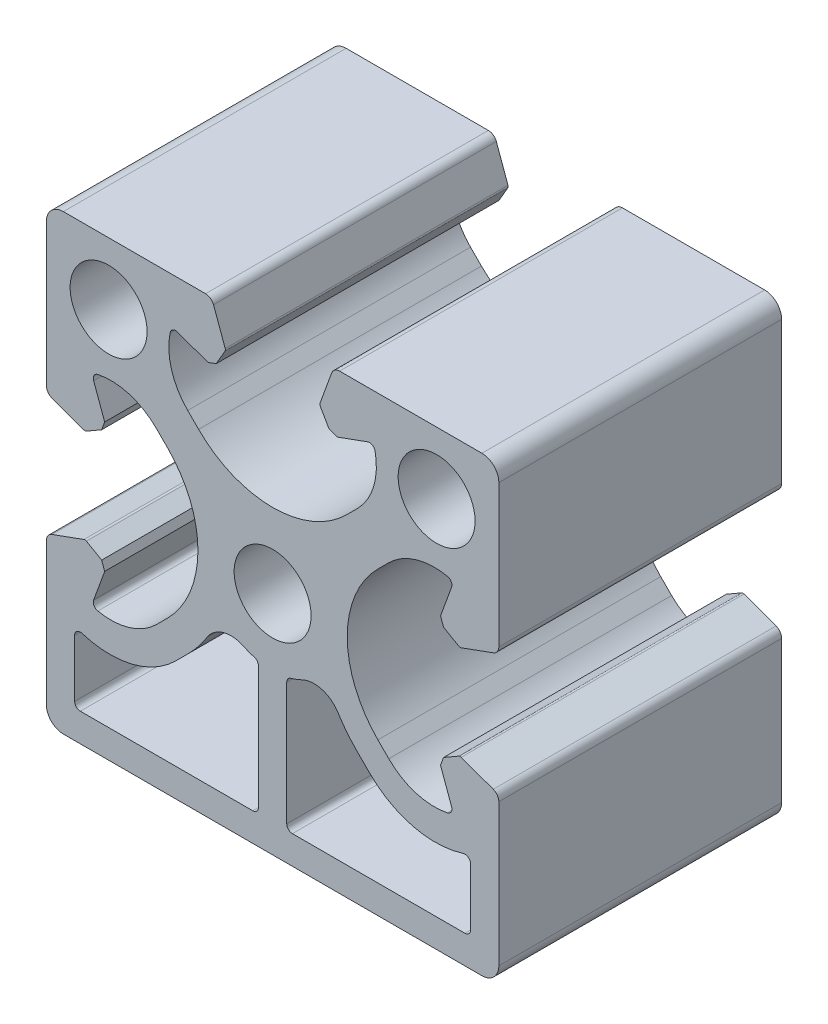
from build123d import *

# Parameters (mm, degrees)
SK_MAIN_EXTRUSION_R  = 3.4
MAIN_EXTRUSION_DEPTH = 25


with BuildPart() as part:
    # Sk Main Extrusion → Main Extrusion (new body)
    with BuildSketch(Plane.XY):
        with BuildLine():
            Line((-16.671180212, -4.190076845), (-19.506515107, -5.222054351))
            ThreePointArc((-19.506515107, -5.222054351), (-19.864364033, -5.496641489), (-20, -5.926823816))
            Line((-20, -5.926823816), (-20, -18.5))
            ThreePointArc((-20, -18.5), (-19.560660172, -19.560660172), (-18.5, -20))
            Line((-18.5, -20), (18.5, -20))
            ThreePointArc((18.5, -20), (19.560660172, -19.560660172), (20, -18.5))
            Line((20, -18.5), (20, -5.926823816))
            ThreePointArc((20, -5.926823816), (19.864364033, -5.496641489), (19.506515107, -5.222054351))
            Line((19.506515107, -5.222054351), (16.671180212, -4.190076845))
            ThreePointArc((16.671180212, -4.190076845), (16.563886241, -4.175951325), (16.460675177, -4.208493649))
            Line((16.460675177, -4.208493649), (15.111296024, -4.987558066))
            Line((15.111296024, -4.987558066), (14.845251581, -5.718509166))
            Line((14.845251581, -5.718509166), (15.81984631, -8.396186179))
            ThreePointArc((15.81984631, -8.396186179), (15.786489799, -8.811074612), (15.450654467, -9.056960151))
            ThreePointArc((15.450654467, -9.056960151), (12.665882372, -8.933433013), (10.272684887, -7.504160339))
            Line((10.272684887, -7.504160339), (9.309262274, -6.540737726))
            ThreePointArc((9.309262274, -6.540737726), (6.6, 0), (9.309262274, 6.540737726))
            Line((9.309262274, 6.540737726), (10.272684887, 7.504160339))
            ThreePointArc((10.272684887, 7.504160339), (12.665882372, 8.933433013), (15.450654467, 9.056960151))
            ThreePointArc((15.450654467, 9.056960151), (15.786489799, 8.811074612), (15.81984631, 8.396186179))
            Line((15.81984631, 8.396186179), (14.845251581, 5.718509166))
            Line((14.845251581, 5.718509166), (15.111296024, 4.987558066))
            Line((15.111296024, 4.987558066), (16.460675177, 4.208493649))
            ThreePointArc((16.460675177, 4.208493649), (16.563886241, 4.175951325), (16.671180212, 4.190076845))
            Line((16.671180212, 4.190076845), (19.506515107, 5.222054351))
            ThreePointArc((19.506515107, 5.222054351), (19.864364033, 5.496641489), (20, 5.926823816))
            Line((20, 5.926823816), (20, 18.5))
            ThreePointArc((20, 18.5), (19.560660172, 19.560660172), (18.5, 20))
            Line((18.5, 20), (5.926823816, 20))
            ThreePointArc((5.926823816, 20), (5.496641489, 19.864364033), (5.222054351, 19.506515107))
            Line((5.222054351, 19.506515107), (4.190076845, 16.671180212))
            ThreePointArc((4.190076845, 16.671180212), (4.175951325, 16.563886241), (4.208493649, 16.460675177))
            Line((4.208493649, 16.460675177), (4.987558066, 15.111296024))
            Line((4.987558066, 15.111296024), (5.718509166, 14.845251581))
            Line((5.718509166, 14.845251581), (8.396186179, 15.81984631))
            ThreePointArc((8.396186179, 15.81984631), (8.811074612, 15.786489799), (9.056960151, 15.450654467))
            ThreePointArc((9.056960151, 15.450654467), (8.933433013, 12.665882372), (7.504160339, 10.272684887))
            Line((7.504160339, 10.272684887), (6.540737726, 9.309262274))
            ThreePointArc((6.540737726, 9.309262274), (0, 6.6), (-6.540737726, 9.309262274))
            Line((-6.540737726, 9.309262274), (-7.504160339, 10.272684887))
            ThreePointArc((-7.504160339, 10.272684887), (-8.933433013, 12.665882372), (-9.056960151, 15.450654467))
            ThreePointArc((-9.056960151, 15.450654467), (-8.811074612, 15.786489799), (-8.396186179, 15.81984631))
            Line((-8.396186179, 15.81984631), (-5.718509166, 14.845251581))
            Line((-5.718509166, 14.845251581), (-4.987558066, 15.111296024))
            Line((-4.987558066, 15.111296024), (-4.208493649, 16.460675177))
            ThreePointArc((-4.208493649, 16.460675177), (-4.175951325, 16.563886241), (-4.190076845, 16.671180212))
            Line((-4.190076845, 16.671180212), (-5.222054351, 19.506515107))
            ThreePointArc((-5.222054351, 19.506515107), (-5.496641489, 19.864364033), (-5.926823816, 20))
            Line((-5.926823816, 20), (-18.5, 20))
            ThreePointArc((-18.5, 20), (-19.560660172, 19.560660172), (-20, 18.5))
            Line((-20, 18.5), (-20, 5.926823816))
            ThreePointArc((-20, 5.926823816), (-19.864364033, 5.496641489), (-19.506515107, 5.222054351))
            Line((-19.506515107, 5.222054351), (-16.671180212, 4.190076845))
            ThreePointArc((-16.671180212, 4.190076845), (-16.563886241, 4.175951325), (-16.460675177, 4.208493649))
            Line((-16.460675177, 4.208493649), (-15.111296024, 4.987558066))
            Line((-15.111296024, 4.987558066), (-14.845251581, 5.718509166))
            Line((-14.845251581, 5.718509166), (-15.81984631, 8.396186179))
            ThreePointArc((-15.81984631, 8.396186179), (-15.786489799, 8.811074612), (-15.450654467, 9.056960151))
            ThreePointArc((-15.450654467, 9.056960151), (-12.665882372, 8.933433013), (-10.272684887, 7.504160339))
            Line((-10.272684887, 7.504160339), (-9.309262274, 6.540737726))
            ThreePointArc((-9.309262274, 6.540737726), (-6.6, 0), (-9.309262274, -6.540737726))
            Line((-9.309262274, -6.540737726), (-10.272684887, -7.504160339))
            ThreePointArc((-10.272684887, -7.504160339), (-12.665882372, -8.933433013), (-15.450654467, -9.056960151))
            ThreePointArc((-15.450654467, -9.056960151), (-15.786489799, -8.811074612), (-15.81984631, -8.396186179))
            Line((-15.81984631, -8.396186179), (-14.845251581, -5.718509166))
            Line((-14.845251581, -5.718509166), (-15.111296024, -4.987558066))
            Line((-15.111296024, -4.987558066), (-16.460675177, -4.208493649))
            ThreePointArc((-16.460675177, -4.208493649), (-16.563886241, -4.175951325), (-16.671180212, -4.190076845))
        make_face()
        with Locations((14.5, 14.5)):
            Circle(SK_MAIN_EXTRUSION_R, mode=Mode.SUBTRACT)
        Circle(SK_MAIN_EXTRUSION_R, mode=Mode.SUBTRACT)
        with Locations((-14.5, 14.5)):
            Circle(SK_MAIN_EXTRUSION_R, mode=Mode.SUBTRACT)
        with BuildLine():
            Line((-7.441495321, -8.308504679), (-8.577273231, -9.444282589))
            ThreePointArc((-8.577273231, -9.444282589), (-12.430514315, -11.611987193), (-16.849169473, -11.464011904))
            ThreePointArc((-16.849169473, -11.464011904), (-17.295452819, -11.537349181), (-17.5, -11.940719521))
            Line((-17.5, -11.940719521), (-17.5, -17))
            ThreePointArc((-17.5, -17), (-17.353553391, -17.353553391), (-17, -17.5))
            Line((-17, -17.5), (-1.75, -17.5))
            ThreePointArc((-1.75, -17.5), (-1.396446609, -17.353553391), (-1.25, -17))
            Line((-1.25, -17), (-1.25, -6.156094541))
            ThreePointArc((-1.25, -6.156094541), (-1.351026708, -5.854730455), (-1.61328125, -5.675149655))
            ThreePointArc((-1.61328125, -5.675149655), (-2.10305366, -5.51245547), (-2.576734694, -5.307583096))
            ThreePointArc((-2.576734694, -5.307583096), (-4.359333373, -5.153883821), (-5.788120301, -6.230846881))
            ThreePointArc((-5.788120301, -6.230846881), (-6.555931161, -7.316529108), (-7.441495321, -8.308504679))
        make_face(mode=Mode.SUBTRACT)
        with BuildLine():
            Line((1.25, -6.156094541), (1.25, -17))
            ThreePointArc((1.25, -17), (1.396446609, -17.353553391), (1.75, -17.5))
            Line((1.75, -17.5), (17, -17.5))
            ThreePointArc((17, -17.5), (17.353553391, -17.353553391), (17.5, -17))
            Line((17.5, -17), (17.5, -11.940719521))
            ThreePointArc((17.5, -11.940719521), (17.295452819, -11.537349181), (16.849169473, -11.464011904))
            ThreePointArc((16.849169473, -11.464011904), (12.430514315, -11.611987193), (8.577273231, -9.444282589))
            Line((8.577273231, -9.444282589), (7.441495321, -8.308504679))
            ThreePointArc((7.441495321, -8.308504679), (6.555931161, -7.316529108), (5.788120301, -6.230846881))
            ThreePointArc((5.788120301, -6.230846881), (4.359333373, -5.153883821), (2.576734694, -5.307583096))
            ThreePointArc((2.576734694, -5.307583096), (2.10305366, -5.51245547), (1.61328125, -5.675149655))
            ThreePointArc((1.61328125, -5.675149655), (1.351026708, -5.854730455), (1.25, -6.156094541))
        make_face(mode=Mode.SUBTRACT)
    extrude(amount=-MAIN_EXTRUSION_DEPTH)


solid = part.part
